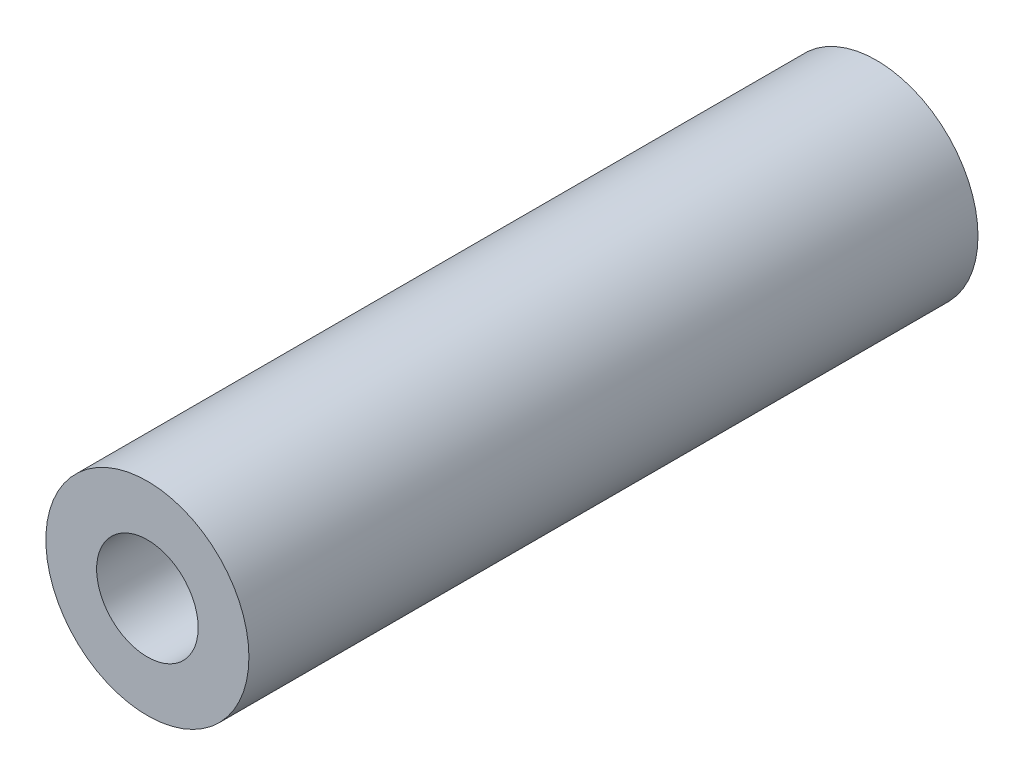
from build123d import *

# Parameters (mm, degrees)
SKETCH1_R                 = 5
BOSS_EXTRUDE1_DEPTH       = 35.9
F_5_0MM_DOWEL_HOLE1_D     = 5
F_5_0MM_DOWEL_HOLE1_DEPTH = 35.9


with BuildPart() as part:
    # Sketch1 → Boss-Extrude1 (new body)
    with BuildSketch(Plane.XY):
        Circle(SKETCH1_R)
    extrude(amount=BOSS_EXTRUDE1_DEPTH)

    # Ø5.0mm Dowel Hole1
    with Locations(Plane.XY.offset(35.9)):
        with Locations((0, 0)):
            Hole(F_5_0MM_DOWEL_HOLE1_D / 2, depth=F_5_0MM_DOWEL_HOLE1_DEPTH)


solid = part.part
